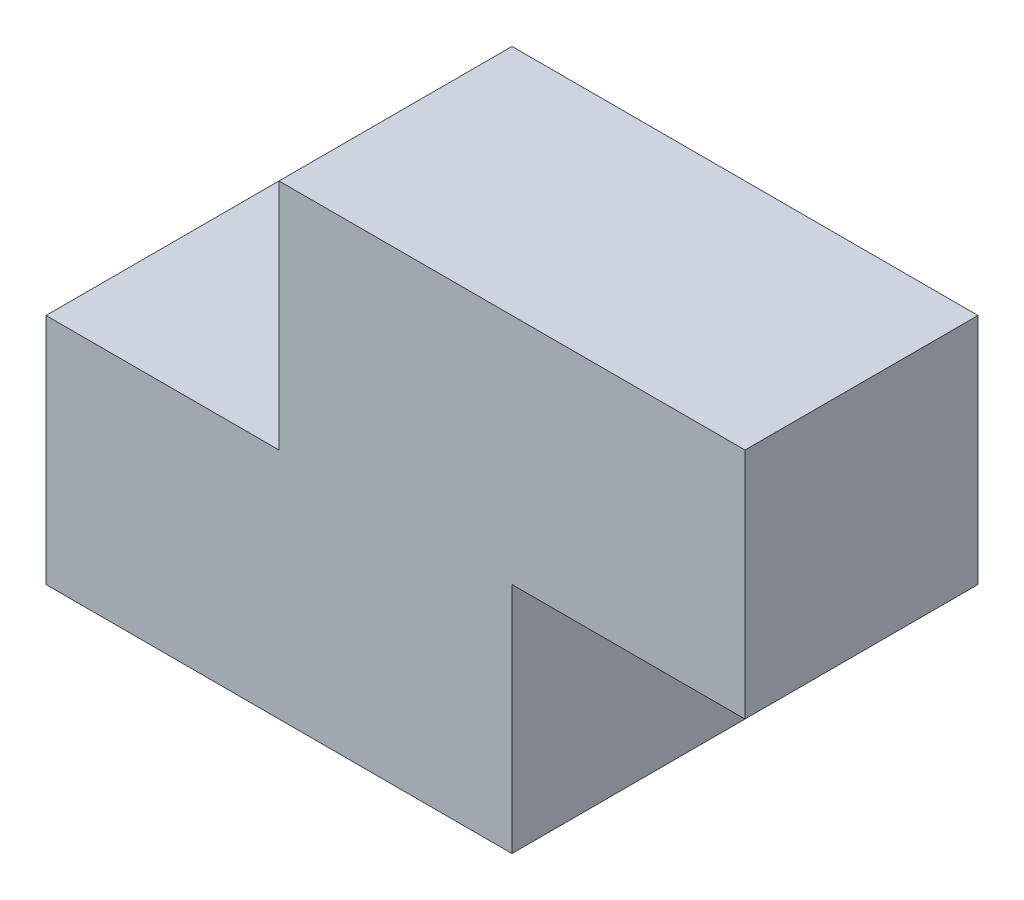
from build123d import *

# Parameters (mm, degrees)
BOSS_EXTRUDE1_DEPTH = 30


with BuildPart() as part:
    # Sketch1 → Boss-Extrude1 (new body)
    with BuildSketch(Plane.XY):
        Polygon((-30, 0), (30, 0), (30, 30), (60, 30), (60, 60), (0, 60), (0, 30), (-30, 30), align=None)
    extrude(amount=-BOSS_EXTRUDE1_DEPTH)


solid = part.part
